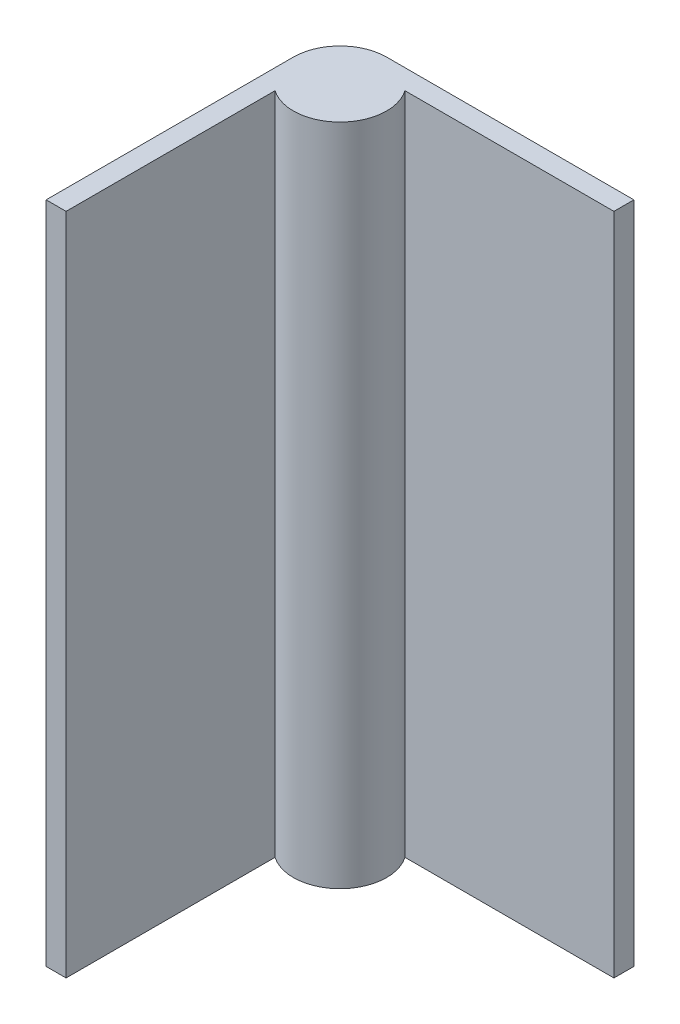
from build123d import *

# Parameters (mm, degrees)
BOSS_EXTRUDE2_DEPTH = 25.62


with BuildPart() as part:
    # Sketch3 → Boss-Extrude2 (new body)
    with BuildSketch(Plane(origin=(0, 0, 0), x_dir=(1, 0, 0), z_dir=(0, 1, 0))):
        with BuildLine():
            ThreePointArc((-4.193822504, 6.7), (-4.397207794, 4.397207794), (-6.7, 4.193822504))
            Line((-6.7, 4.193822504), (-6.7, 3.87))
            Line((-6.7, 3.87), (-6.7, -3.87))
            Line((-6.7, -3.87), (-7.47, -3.87))
            Line((-7.47, -3.87), (-7.47, 3.87))
            Line((-7.47, 3.87), (-7.47, 5.67))
            ThreePointArc((-7.47, 5.67), (-6.942792206, 6.942792206), (-5.67, 7.47))
            Line((-5.67, 7.47), (-3.87, 7.47))
            Line((-3.87, 7.47), (3.87, 7.47))
            Line((3.87, 7.47), (3.87, 6.7))
            Line((3.87, 6.7), (-3.87, 6.7))
            Line((-3.87, 6.7), (-4.193822504, 6.7))
        make_face()
    extrude(amount=BOSS_EXTRUDE2_DEPTH)


solid = part.part
